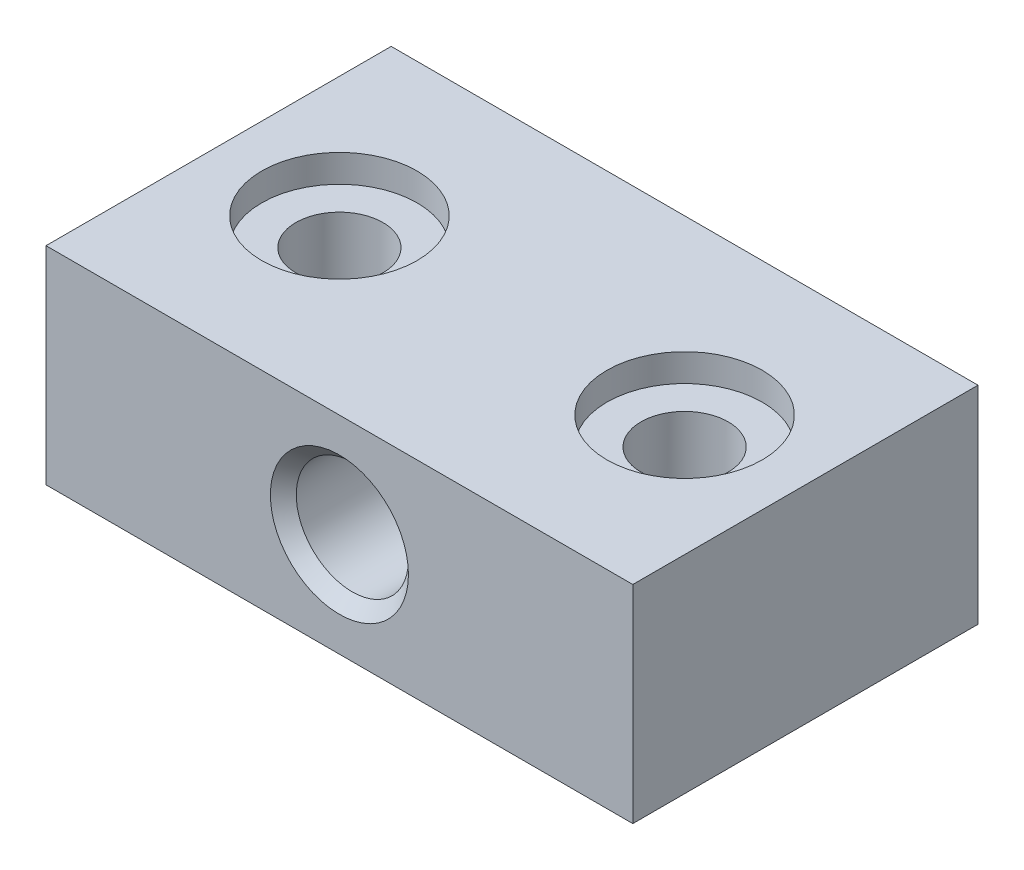
from build123d import *

# Parameters (mm, degrees)
SKETCH1_W           = 34
SKETCH1_H           = 12
BOSS_EXTRUDE1_DEPTH = 20
SKETCH2_R           = 3.25
CUT_EXTRUDE1_DEPTH  = 20
SKETCH3_R           = 2.525
CUT_EXTRUDE2_DEPTH  = 20
SKETCH4_R           = 4.5
CUT_EXTRUDE3_DEPTH  = 1.6
CUT_EXTRUDE4_DEPTH  = 4.97
CHAMFER1_SIZE       = 0.75
CHAMFER2_SIZE       = 0.75


with BuildPart() as part:
    # Sketch1 → Boss-Extrude1 (new body)
    with BuildSketch(Plane.XY):
        Rectangle(SKETCH1_W, SKETCH1_H)
    extrude(amount=-BOSS_EXTRUDE1_DEPTH)

    # Sketch2 → Cut-Extrude1 (cut)
    with BuildSketch(Plane.XY):
        Circle(SKETCH2_R)
    extrude(amount=-CUT_EXTRUDE1_DEPTH, mode=Mode.SUBTRACT)

    # Sketch3 → Cut-Extrude2 (cut)
    with BuildSketch(Plane(origin=(0, 6, 0), x_dir=(1, 0, 0), z_dir=(0, 1, 0))):
        with Locations((-10, 10)):
            Circle(SKETCH3_R)
        with Locations((10, 10)):
            Circle(SKETCH3_R)
    extrude(amount=-CUT_EXTRUDE2_DEPTH, mode=Mode.SUBTRACT)

    # Sketch4 → Cut-Extrude3 (cut)
    with BuildSketch(Plane(origin=(0, 6, 0), x_dir=(1, 0, 0), z_dir=(0, 1, 0))):
        with Locations((-10, 10)):
            Circle(SKETCH4_R)
        with Locations((10, 10)):
            Circle(SKETCH4_R)
    extrude(amount=-CUT_EXTRUDE3_DEPTH, mode=Mode.SUBTRACT)

    # Sketch5 → Cut-Extrude4 (cut)
    with BuildSketch(Plane.XZ.offset(6)):
        Polygon((10, -5.38), (5.998962635, -7.69), (5.998962635, -12.31), (10, -14.62), (14.001037365, -12.31), (14.001037365, -7.69), align=None)
        Polygon((-10, -5.38), (-14.001037365, -7.69), (-14.001037365, -12.31), (-10, -14.62), (-5.998962635, -12.31), (-5.998962635, -7.69), align=None)
    extrude(amount=-CUT_EXTRUDE4_DEPTH, mode=Mode.SUBTRACT)

    # Chamfer1
    chamfer1_edges = [part.edges().sort_by_distance(p)[0] for p in [
        (-3.25, 0, -20),
    ]]
    chamfer(chamfer1_edges, length=CHAMFER1_SIZE)

    # Chamfer2
    chamfer2_edges = [part.edges().sort_by_distance(p)[0] for p in [
        (-3.25, 0, 0),
    ]]
    chamfer(chamfer2_edges, length=CHAMFER2_SIZE)


solid = part.part
